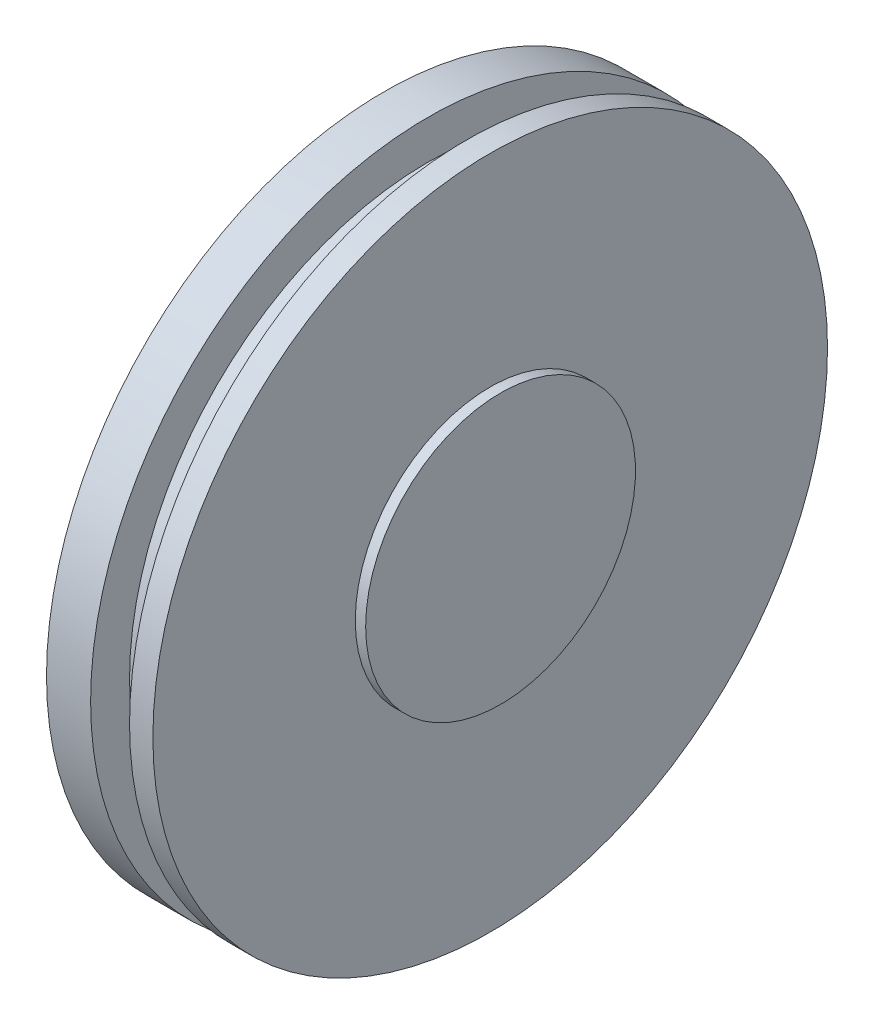
from build123d import *


with BuildPart() as part:
    # Esquisse1 → Base-Révolution (revolve)
    with BuildSketch(Plane.XY, mode=Mode.PRIVATE) as base_r_volution_sk:
        Polygon((-0.4, 13), (-1.3, 13), (-1.3, 11.5), (-2.8, 11.5), (-2.8, 13), (-4.5, 13), (-4.5, 0), (0, 0), (0, 5.2), (-0.4, 5.2), align=None)
    revolve(base_r_volution_sk.sketch.rotate(Axis((-3.74521028, 0, 0), (1, 0, 0)), 90), axis=Axis((-3.74521028, 0, 0), (1, 0, 0)))  # turned: the seam where the file's is


solid = part.part
